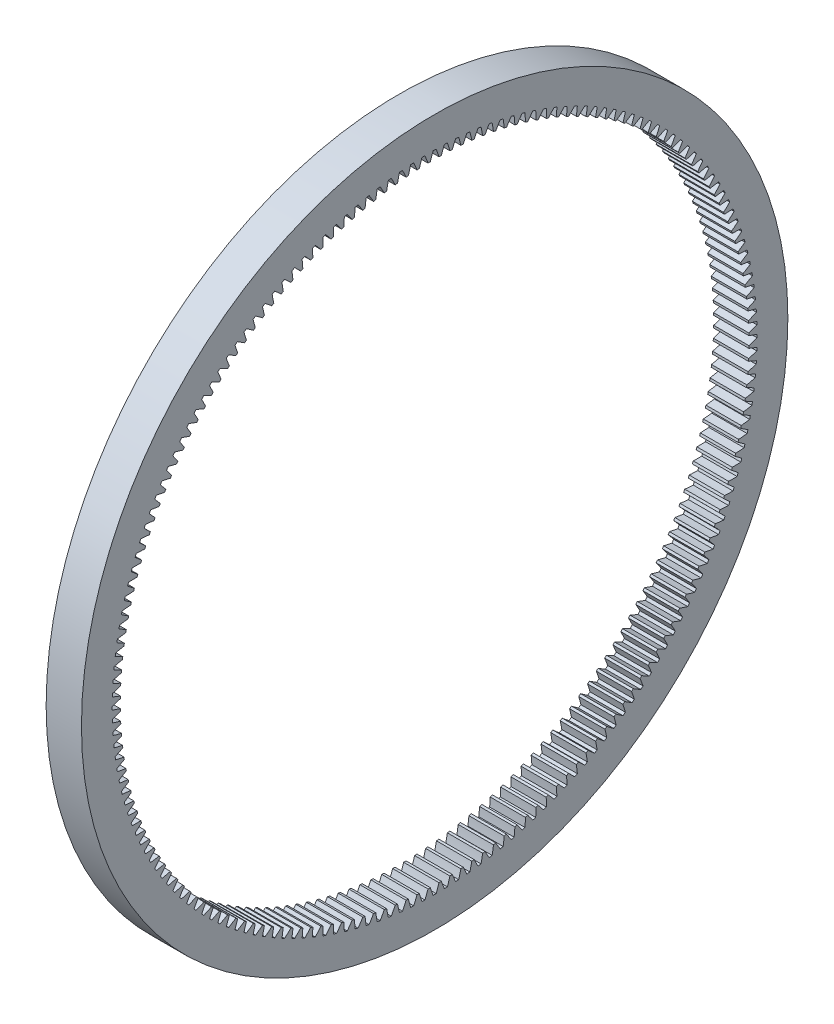
from build123d import *

# Parameters (mm, degrees)
BASPROSKE_W     = 6.35
BASPROSKE_H     = 6.985
TOOTHCUT_DEPTH  = 91.02678768
TEETHCUTS_COUNT = 180
TEETHCUTS_ANGLE = 358


with BuildPart() as part:
    # BasProSke → Base-Revolve (revolve)
    with BuildSketch(Plane(origin=(0, 0, 0), x_dir=(1, 0, 0), z_dir=(0, 1, 0))):
        with Locations((3.175, 60.0075)):
            Rectangle(BASPROSKE_W, BASPROSKE_H)
    revolve(axis=Axis((-10, 0, 0), (1, 0, 0)))

    # TooCutSke → ToothCut (cut, through all)
    with BuildSketch(Plane(origin=(0, 0, 0), x_dir=(0, 0, -1), z_dir=(1, 0, 0))):
        with BuildLine():
            ThreePointArc((0.780564766, 56.484206879), (0.534843954, 57.226692969), (0.268895445, 57.96217628))
            ThreePointArc((0.268895445, 57.96217628), (0, 57.9628), (-0.268895445, 57.96217628))
            ThreePointArc((-0.268895445, 57.96217628), (-0.534843954, 57.226692969), (-0.780564766, 56.484206879))
            ThreePointArc((-0.780564766, 56.484206879), (0, 56.4896), (0.780564766, 56.484206879))
        make_face()
    toothcut = extrude(amount=TOOTHCUT_DEPTH, mode=Mode.SUBTRACT)

    # TeethCuts: ToothCut ×180 about axis
    teethcuts_axis = Axis((-10, 0, 0), (1, 0, 0))
    for i in range(1, TEETHCUTS_COUNT):
        add(toothcut.rotate(teethcuts_axis, i * TEETHCUTS_ANGLE / (TEETHCUTS_COUNT - 1)), mode=Mode.SUBTRACT)


solid = part.part
